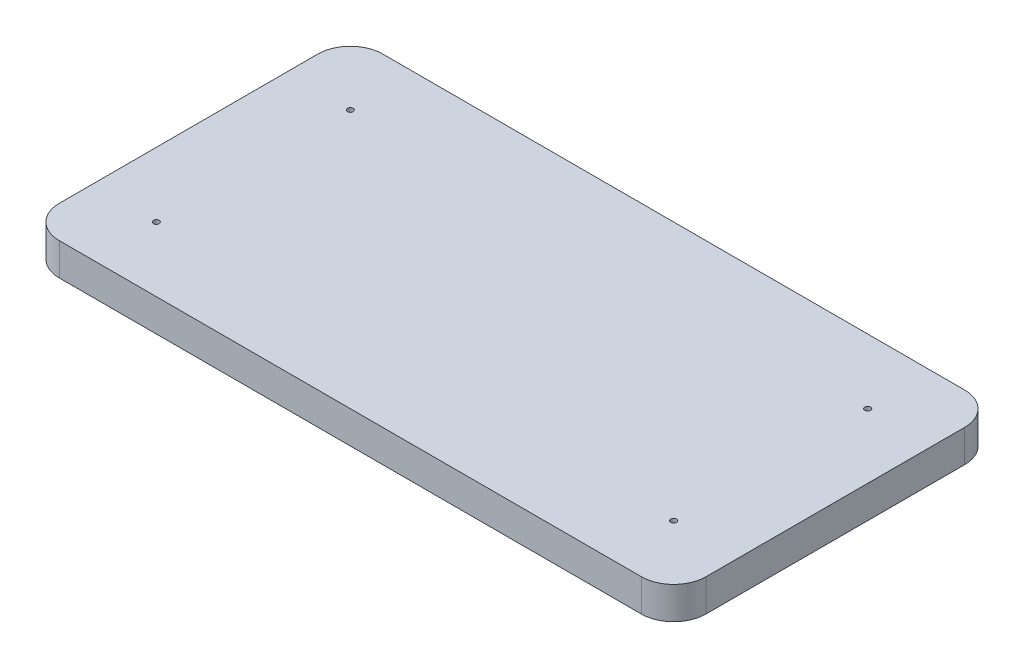
from build123d import *

# Parameters (mm, degrees)
SKETCH1_W              = 5080
SKETCH1_H              = 2540
BOSS_EXTRUDE1_DEPTH    = 254
F_2_4_5_TAPPED_HOLE1_D = 45.24248
FILLET1_R              = 254


with BuildPart() as part:
    # Sketch1 → Boss-Extrude1 (new body)
    with BuildSketch(Plane(origin=(0, 0, 0), x_dir=(1, 0, 0), z_dir=(0, 1, 0))):
        Rectangle(SKETCH1_W, SKETCH1_H)
    extrude(amount=BOSS_EXTRUDE1_DEPTH)

    # 2-4.5 Tapped Hole1 (through all)
    with Locations(Plane(origin=(-2032, 254, 762), x_dir=(0, 0, 1), z_dir=(0, 1, 0))):
        with Locations((0, 0), (-1524, 0), (-1524, 4064), (0, 4064)):
            Hole(F_2_4_5_TAPPED_HOLE1_D / 2)

    # Fillet1
    fillet1_edges = [part.edges().sort_by_distance(p)[0] for p in [
        (2540, 127, 1270),
        (-2540, 127, 1270),
        (-2540, 127, -1270),
        (2540, 127, -1270),
    ]]
    fillet(fillet1_edges, radius=FILLET1_R)


solid = part.part
